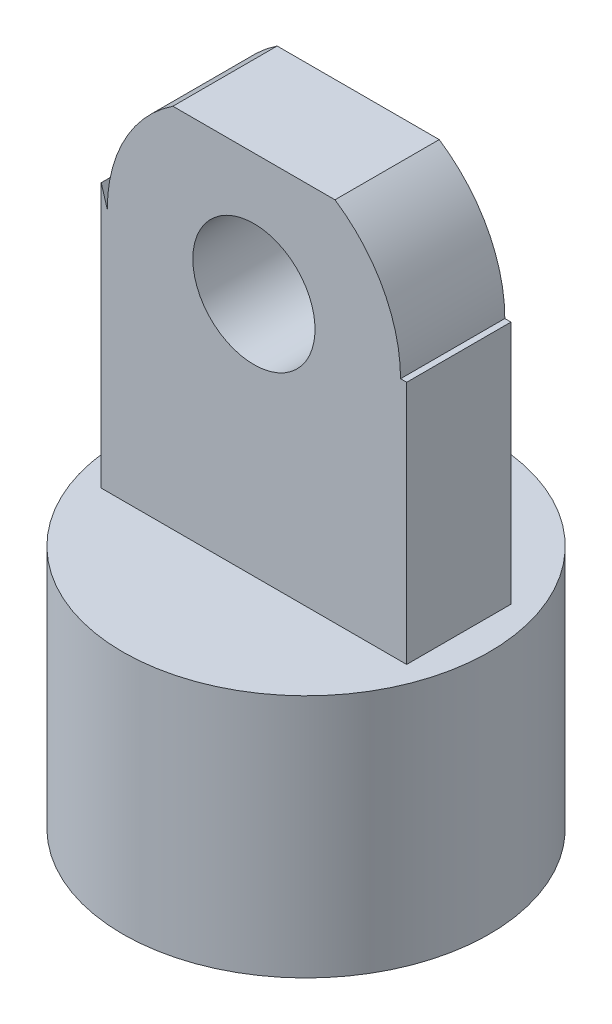
from build123d import *

# Parameters (mm, degrees)
SKETCH1_R           = 15
BOSS_EXTRUDE1_DEPTH = 20
SKETCH2_R           = 7.5
CUT_EXTRUDE1_DEPTH  = 10
SKETCH3_W           = 25
SKETCH3_H           = 8.533910502
BOSS_EXTRUDE2_DEPTH = 30
SKETCH4_R           = 5
CUT_EXTRUDE2_DEPTH  = 30
SKETCH5_R           = 7.5
BOSS_EXTRUDE3_DEPTH = 15


with BuildPart() as part:
    # Sketch1 → Boss-Extrude1 (new body)
    with BuildSketch(Plane(origin=(0, 0, 0), x_dir=(1, 0, 0), z_dir=(0, 1, 0))):
        Circle(SKETCH1_R)
    extrude(amount=BOSS_EXTRUDE1_DEPTH)

    # Sketch2 → Cut-Extrude1 (cut)
    with BuildSketch(Plane.XZ):
        Circle(SKETCH2_R)
    extrude(amount=-CUT_EXTRUDE1_DEPTH, mode=Mode.SUBTRACT)

    # Sketch3 → Boss-Extrude2 (add)
    with BuildSketch(Plane(origin=(0, 20, 0), x_dir=(1, 0, 0), z_dir=(0, 1, 0))):
        Rectangle(SKETCH3_W, SKETCH3_H)
    extrude(amount=BOSS_EXTRUDE2_DEPTH)

    # Sketch4 → Cut-Extrude2 (cut)
    with BuildSketch(Plane(origin=(0, 0, -4.266955251), x_dir=(-1, 0, 0), z_dir=(0, 0, -1))):
        with Locations((0, 40)):
            Circle(SKETCH4_R)
        with BuildLine():
            Line((12, 112.846805037), (20.699554593, 68.640446889))
            Line((20.699554593, 68.640446889), (12, 40))
            ThreePointArc((12, 40), (0, 52), (-12, 40))
            Line((-12, 40), (-18.346894815, 40))
            Line((-18.346894815, 40), (-15.704364739, 112.846805037))
            Line((-15.704364739, 112.846805037), (12, 112.846805037))
        make_face()
    extrude(amount=-CUT_EXTRUDE2_DEPTH, mode=Mode.SUBTRACT)

    # Sketch5 → Boss-Extrude3 (add)
    with BuildSketch(Plane.XZ.offset(-10)):
        Circle(SKETCH5_R)
    extrude(amount=BOSS_EXTRUDE3_DEPTH)


solid = part.part
